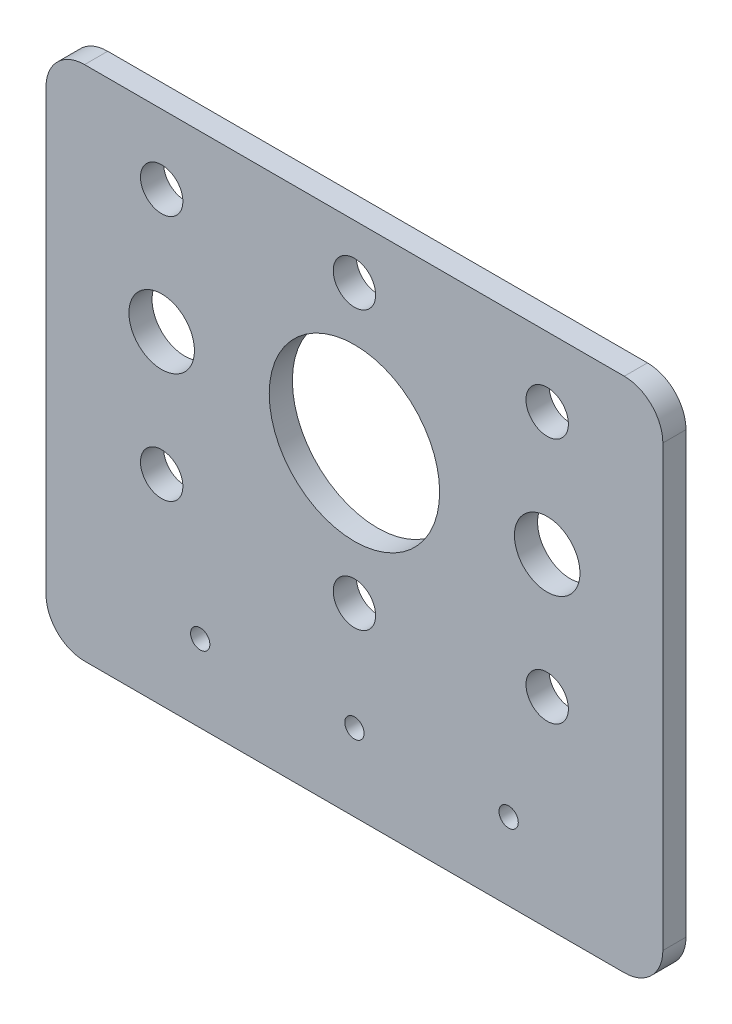
from build123d import *

# Parameters (mm, degrees)
SKETCH_1_R      = 11.05
SKETCH_1_R_2    = 2.75
SKETCH_1_R_3    = 1.25
SKETCH_1_R_4    = 4.25
EXTRUDE_1_DEPTH = 3


with BuildPart() as part:
    # 草图1 → 凸台-拉伸1 (new body)
    with BuildSketch(Plane.XY):
        with BuildLine():
            Line((-40, 20), (-40, -37))
            ThreePointArc((-40, -37), (-38.535533906, -40.535533906), (-35, -42))
            Line((-35, -42), (35, -42))
            ThreePointArc((35, -42), (38.535533906, -40.535533906), (40, -37))
            Line((40, -37), (40, 20))
            ThreePointArc((40, 20), (38.535533906, 23.535533906), (35, 25))
            Line((35, 25), (-35, 25))
            ThreePointArc((-35, 25), (-38.535533906, 23.535533906), (-40, 20))
        make_face()
        Circle(SKETCH_1_R, mode=Mode.SUBTRACT)
        with Locations((-25, 16)):
            Circle(SKETCH_1_R_2, mode=Mode.SUBTRACT)
        with Locations((-25, -16)):
            Circle(SKETCH_1_R_2, mode=Mode.SUBTRACT)
        with Locations((25, -16)):
            Circle(SKETCH_1_R_2, mode=Mode.SUBTRACT)
        with Locations((25, 16)):
            Circle(SKETCH_1_R_2, mode=Mode.SUBTRACT)
        with Locations((0, -32)):
            Circle(SKETCH_1_R_3, mode=Mode.SUBTRACT)
        with Locations((-20, -32)):
            Circle(SKETCH_1_R_3, mode=Mode.SUBTRACT)
        with Locations((20, -32)):
            Circle(SKETCH_1_R_3, mode=Mode.SUBTRACT)
        with Locations((-25, 0)):
            Circle(SKETCH_1_R_4, mode=Mode.SUBTRACT)
        with Locations((25, 0)):
            Circle(SKETCH_1_R_4, mode=Mode.SUBTRACT)
        with Locations((0, 18)):
            Circle(SKETCH_1_R_2, mode=Mode.SUBTRACT)
        with Locations((0, -18)):
            Circle(SKETCH_1_R_2, mode=Mode.SUBTRACT)
    extrude(amount=EXTRUDE_1_DEPTH)


solid = part.part
